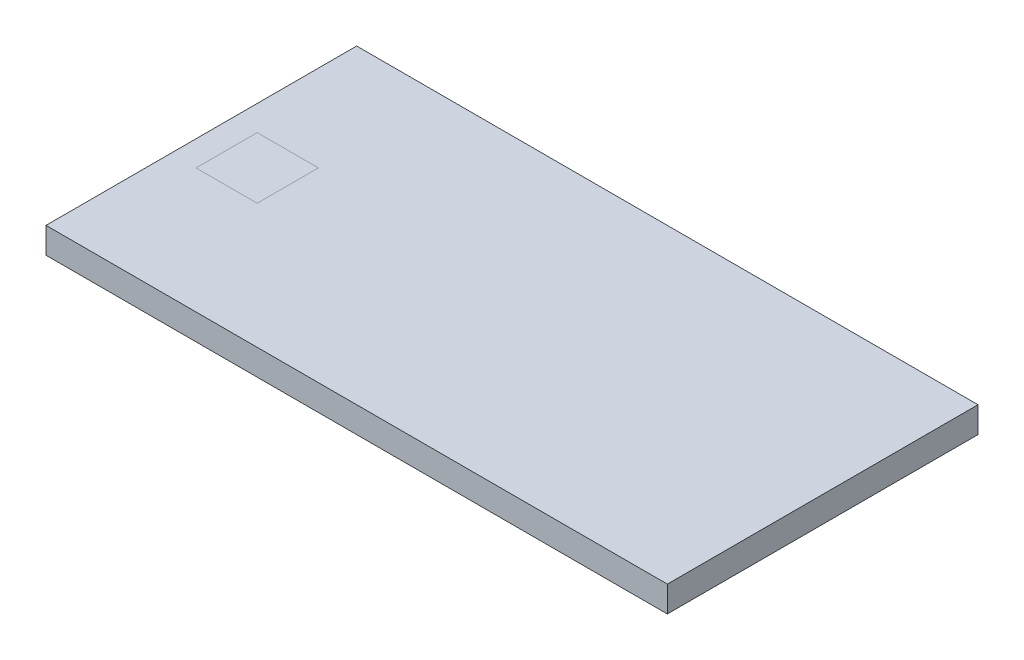
from build123d import *

# Parameters (mm, degrees)
BOSS_EXTRUDE1_DEPTH = 914.4
BOSS_EXTRUDE2_DEPTH = 457.2


with BuildPart() as part:
    # Sketch1 → Boss-Extrude1 (new body, symmetric)
    with BuildSketch(Plane(origin=(0, 0, 0), x_dir=(0, 0, -1), z_dir=(1, 0, 0))):
        Polygon((-457.2, 0), (457.2, 0), (457.2, -76.2), (381, -76.2), (381, -69.85), (450.85, -69.85), (450.85, -6.35), (-450.85, -6.35), (-450.85, -69.85), (-381, -69.85), (-381, -76.2), (-457.2, -76.2), align=None)
    extrude(amount=BOSS_EXTRUDE1_DEPTH, both=True)

    # Sketch2 → Boss-Extrude2 (add, symmetric)
    with BuildSketch(Plane.XY):
        Polygon((-914.4, 0), (-914.4, -76.2), (-838.2, -76.2), (-838.2, -69.85), (-908.05, -69.85), (-908.05, 0), align=None)
        Polygon((908.05, 0), (914.4, 0), (914.4, -76.2), (838.2, -76.2), (838.2, -69.85), (908.05, -69.85), align=None)
    extrude(amount=BOSS_EXTRUDE2_DEPTH, both=True)


solid = part.part
